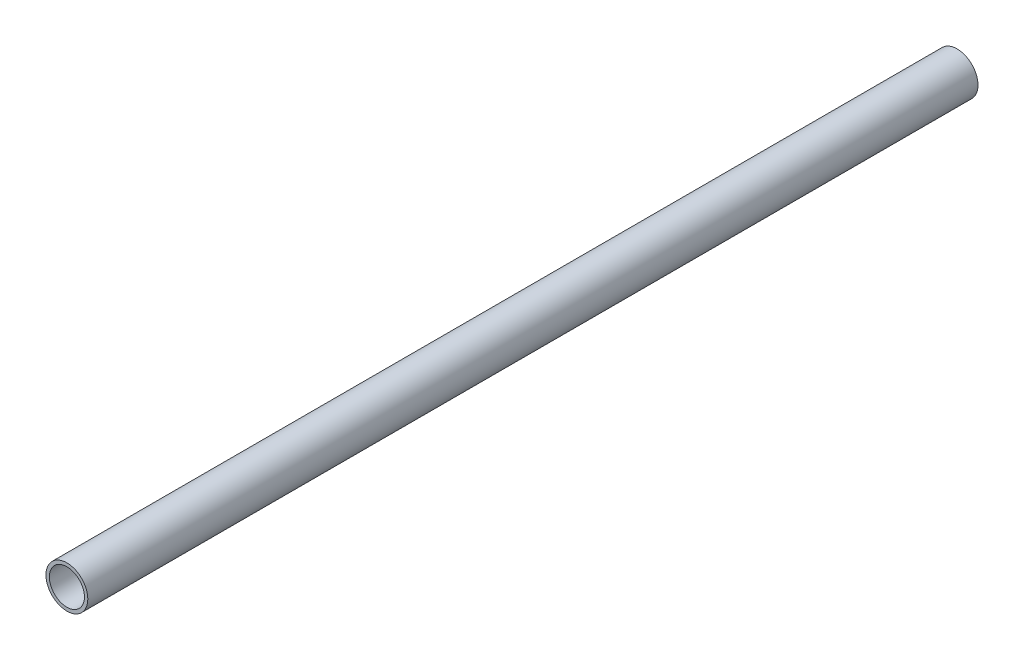
from build123d import *

# Parameters (mm, degrees)
SZKIC1_R                         = 8.35
SZKIC1_R_2                       = 7
DODANIE_WYCI_GNI_CIE1_DEPTH      = 16.7
DODANIE_WYCI_GNI_CIE1_DEPTH_BACK = 338.51975


with BuildPart() as part:
    # Szkic1 → Dodanie-wyciągnięcie1 (new body, two sides)
    with BuildSketch(Plane.XY) as dodanie_wyci_gni_cie1_sk:
        Circle(SZKIC1_R)
        Circle(SZKIC1_R_2, mode=Mode.SUBTRACT)
    extrude(amount=DODANIE_WYCI_GNI_CIE1_DEPTH)
    extrude(dodanie_wyci_gni_cie1_sk.sketch, amount=-DODANIE_WYCI_GNI_CIE1_DEPTH_BACK)


solid = part.part
